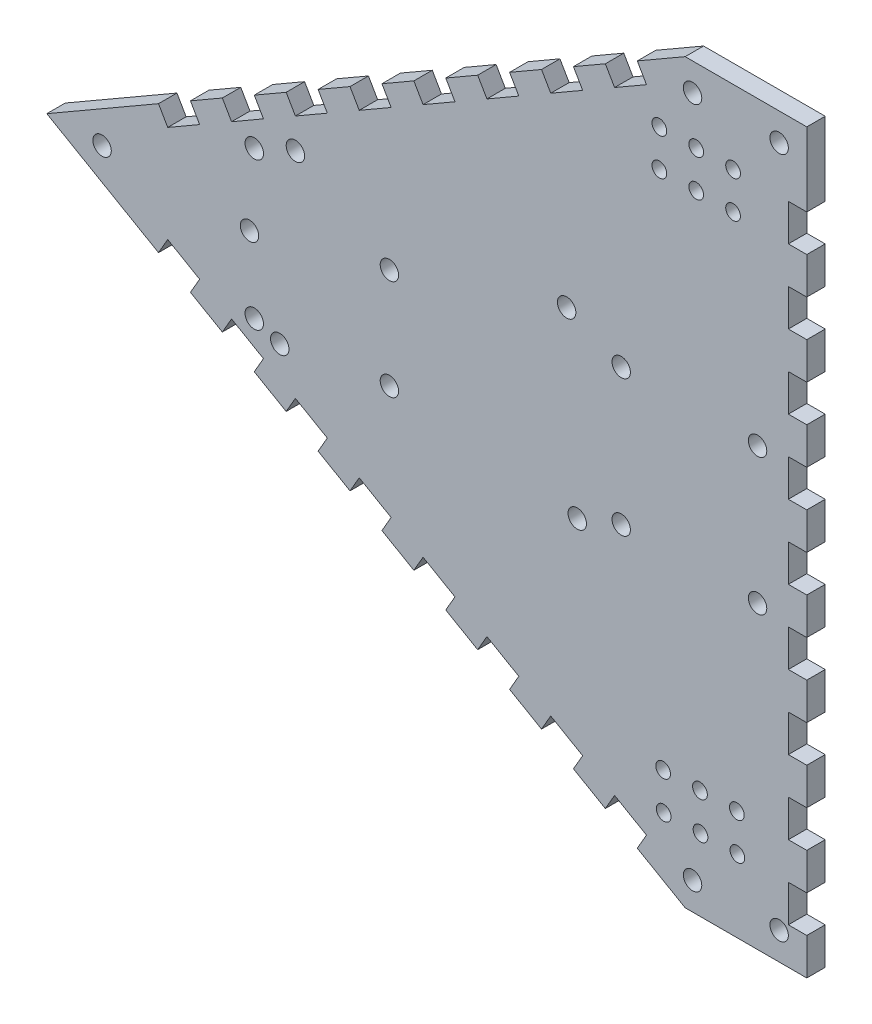
from build123d import *

# Parameters (mm, degrees)
SKETCH1_R               = 2
BOSS_EXTRUDE1_DEPTH     = 5
SKETCH2_R               = 2.5
CUT_EXTRUDE1_DEPTH      = 1
CUT_EXTRUDE1_DEPTH_BACK = 6
SKETCH3_R               = 2.5
SKETCH3_W               = 5
SKETCH3_H               = 10
CUT_EXTRUDE5_DEPTH      = 1
CUT_EXTRUDE5_DEPTH_BACK = 6


with BuildPart() as part:
    # Sketch1 → Boss-Extrude1 (new body)
    with BuildSketch(Plane.XY):
        Polygon((2.5, 0), (-30.5, 0), (-203.705080757, -100), (-30.5, -200), (2.5, -200), align=None)
        with Locations((-17.5, -20)):
            Circle(SKETCH1_R, mode=Mode.SUBTRACT)
        with Locations((-27.5, -20)):
            Circle(SKETCH1_R, mode=Mode.SUBTRACT)
        with Locations((-37.5, -20)):
            Circle(SKETCH1_R, mode=Mode.SUBTRACT)
        with Locations((-27.5, -30)):
            Circle(SKETCH1_R, mode=Mode.SUBTRACT)
        with Locations((-37.5, -30)):
            Circle(SKETCH1_R, mode=Mode.SUBTRACT)
        with Locations((-17.5, -30)):
            Circle(SKETCH1_R, mode=Mode.SUBTRACT)
        with Locations((-36.32829598, -180.575203576)):
            Circle(SKETCH1_R, mode=Mode.SUBTRACT)
        with Locations((-26.329360823, -180.429272995)):
            Circle(SKETCH1_R, mode=Mode.SUBTRACT)
        with Locations((-26.475291404, -170.430337839)):
            Circle(SKETCH1_R, mode=Mode.SUBTRACT)
        with Locations((-16.476356247, -170.284407258)):
            Circle(SKETCH1_R, mode=Mode.SUBTRACT)
        with Locations((-16.330425667, -180.283342414)):
            Circle(SKETCH1_R, mode=Mode.SUBTRACT)
        with Locations((-36.474226561, -170.576268419)):
            Circle(SKETCH1_R, mode=Mode.SUBTRACT)
    extrude(amount=BOSS_EXTRUDE1_DEPTH)

    # Sketch2 → Cut-Extrude1 (cut, two sides)
    with BuildSketch(Plane.XY.offset(5)) as cut_extrude1_sk:
        with Locations((-188.705080757, -100)):
            Circle(SKETCH2_R)
        with Locations((-5, -192.5)):
            Circle(SKETCH2_R)
        with Locations((-10.85, -118.605720398)):
            Circle(SKETCH2_R)
        with Locations((-47.85, -118.605720398)):
            Circle(SKETCH2_R)
        with Locations((-5, -7.5)):
            Circle(SKETCH2_R)
        with Locations((-47.85, -81.605720398)):
            Circle(SKETCH2_R)
        with Locations((-28.490381057, -192.5)):
            Circle(SKETCH2_R)
        with Locations((-10.85, -81.605720398)):
            Circle(SKETCH2_R)
        with Locations((-28.490381057, -7.5)):
            Circle(SKETCH2_R)
    extrude(amount=CUT_EXTRUDE1_DEPTH, mode=Mode.SUBTRACT)
    extrude(cut_extrude1_sk.sketch, amount=-CUT_EXTRUDE1_DEPTH_BACK, mode=Mode.SUBTRACT)

    # Sketch3 → Cut-Extrude5 (cut, two sides)
    with BuildSketch(Plane.XY.offset(5)) as cut_extrude5_sk:
        with Locations((-136.253175473, -75)):
            Circle(SKETCH3_R)
        with Locations((-62.653175473, -75)):
            Circle(SKETCH3_R)
        with Locations((-140.495575744, -122.5)):
            Circle(SKETCH3_R)
        with Locations((-59.775575744, -123.169872981)):
            Circle(SKETCH3_R)
        with Locations((-110.745575744, -117.5)):
            Circle(SKETCH3_R)
        with Locations((-110.745575744, -90.25)):
            Circle(SKETCH3_R)
        with Locations((-148.705080757, -100)):
            Circle(SKETCH3_R)
        with Locations((-147.413429511, -80)):
            Circle(SKETCH3_R)
        with Locations((-147.413429511, -120)):
            Circle(SKETCH3_R)
        Polygon((-121.432667397, -52.5), (-112.77241336, -47.5), (-110.27241336, -51.830127019), (-118.932667397, -56.830127019), align=None)
        Polygon((-101.612159322, -46.830127019), (-104.112159322, -42.5), (-95.451905284, -37.5), (-92.951905284, -41.830127019), align=None)
        Polygon((-84.291651246, -36.830127019), (-86.791651246, -32.5), (-78.131397208, -27.5), (-75.631397208, -31.830127019), align=None)
        Polygon((-66.97114317, -26.830127019), (-69.47114317, -22.5), (-60.810889132, -17.5), (-58.310889132, -21.830127019), align=None)
        Polygon((-49.650635095, -16.830127019), (-52.150635095, -12.5), (-43.490381057, -7.5), (-40.990381057, -11.830127019), align=None)
        Polygon((-136.253175473, -66.830127019), (-138.753175473, -62.5), (-130.092921435, -57.5), (-127.592921435, -61.830127019), align=None)
        Polygon((-153.573683549, -76.830127019), (-156.073683549, -72.5), (-147.413429511, -67.5), (-144.913429511, -71.830127019), align=None)
        Polygon((-170.894191624, -86.830127019), (-173.394191624, -82.5), (-164.733937587, -77.5), (-162.233937587, -81.830127019), align=None)
        Polygon((-112.77241336, -152.5), (-110.27241336, -148.169872981), (-118.932667397, -143.169872981), (-121.432667397, -147.5), align=None)
        Polygon((-173.394191624, -117.5), (-164.733937587, -122.5), (-162.233937587, -118.169872981), (-170.894191624, -113.169872981), align=None)
        Polygon((-156.073683549, -127.5), (-147.413429511, -132.5), (-144.913429511, -128.169872981), (-153.573683549, -123.169872981), align=None)
        Polygon((-138.753175473, -137.5), (-130.092921435, -142.5), (-127.592921435, -138.169872981), (-136.253175473, -133.169872981), align=None)
        Polygon((-52.150635095, -187.5), (-43.490381057, -192.5), (-40.990381057, -188.169872981), (-49.650635095, -183.169872981), align=None)
        Polygon((-69.47114317, -177.5), (-60.810889132, -182.5), (-58.310889132, -178.169872981), (-66.97114317, -173.169872981), align=None)
        Polygon((-86.791651246, -167.5), (-78.131397208, -172.5), (-75.631397208, -168.169872981), (-84.291651246, -163.169872981), align=None)
        Polygon((-104.112159322, -157.5), (-95.451905284, -162.5), (-92.951905284, -158.169872981), (-101.612159322, -153.169872981), align=None)
        with Locations((0, -85)):
            Rectangle(SKETCH3_W, SKETCH3_H)
        with Locations((0, -105)):
            Rectangle(SKETCH3_W, SKETCH3_H)
        with Locations((0, -65)):
            Rectangle(SKETCH3_W, SKETCH3_H)
        with Locations((0, -45)):
            Rectangle(SKETCH3_W, SKETCH3_H)
        with Locations((0, -25)):
            Rectangle(SKETCH3_W, SKETCH3_H)
        with Locations((0, -125)):
            Rectangle(SKETCH3_W, SKETCH3_H)
        with Locations((0, -145)):
            Rectangle(SKETCH3_W, SKETCH3_H)
        with Locations((0, -165)):
            Rectangle(SKETCH3_W, SKETCH3_H)
        with Locations((0, -185)):
            Rectangle(SKETCH3_W, SKETCH3_H)
    extrude(amount=CUT_EXTRUDE5_DEPTH, mode=Mode.SUBTRACT)
    extrude(cut_extrude5_sk.sketch, amount=-CUT_EXTRUDE5_DEPTH_BACK, mode=Mode.SUBTRACT)


solid = part.part
